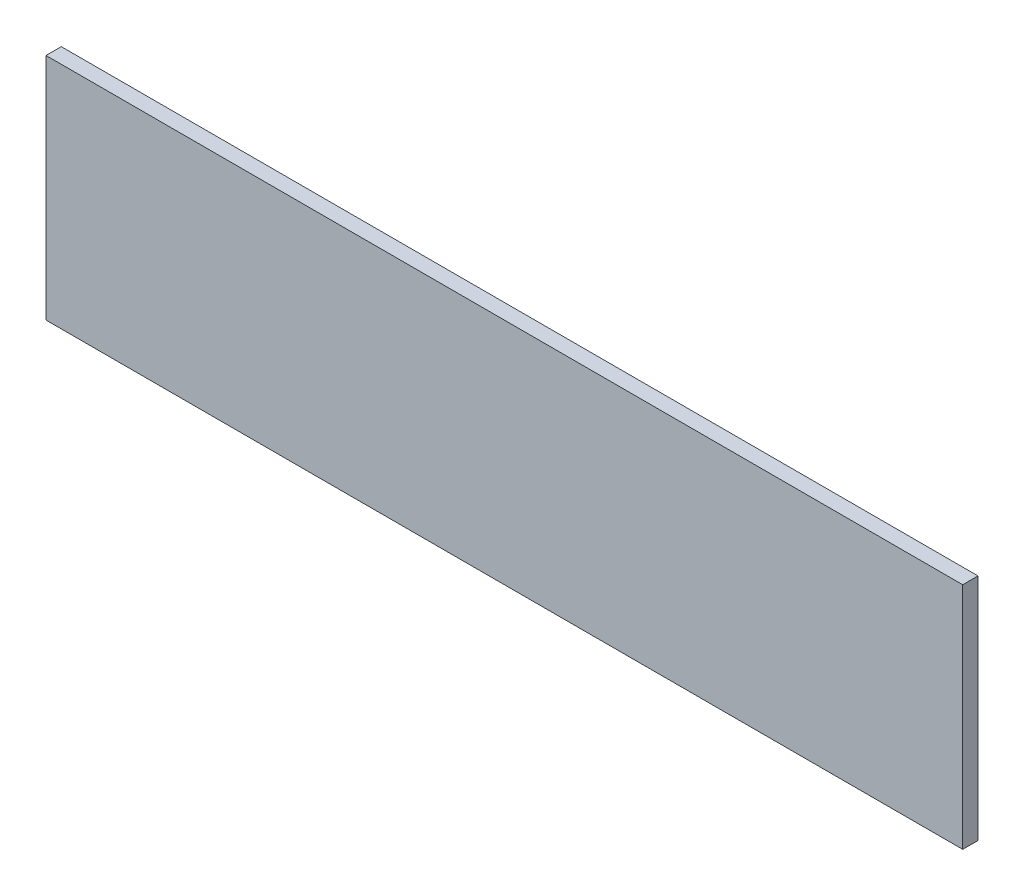
from build123d import *

# Parameters (mm, degrees)
SKETCH_1_W      = 24
SKETCH_1_H      = 6
EXTRUDE_1_DEPTH = 0.4


with BuildPart() as part:
    # ｽｹｯﾁ1 → ﾎﾞｽ - 押し出し1 (new body)
    with BuildSketch(Plane.XY):
        with Locations((12, 3)):
            Rectangle(SKETCH_1_W, SKETCH_1_H)
    extrude(amount=EXTRUDE_1_DEPTH)


solid = part.part
